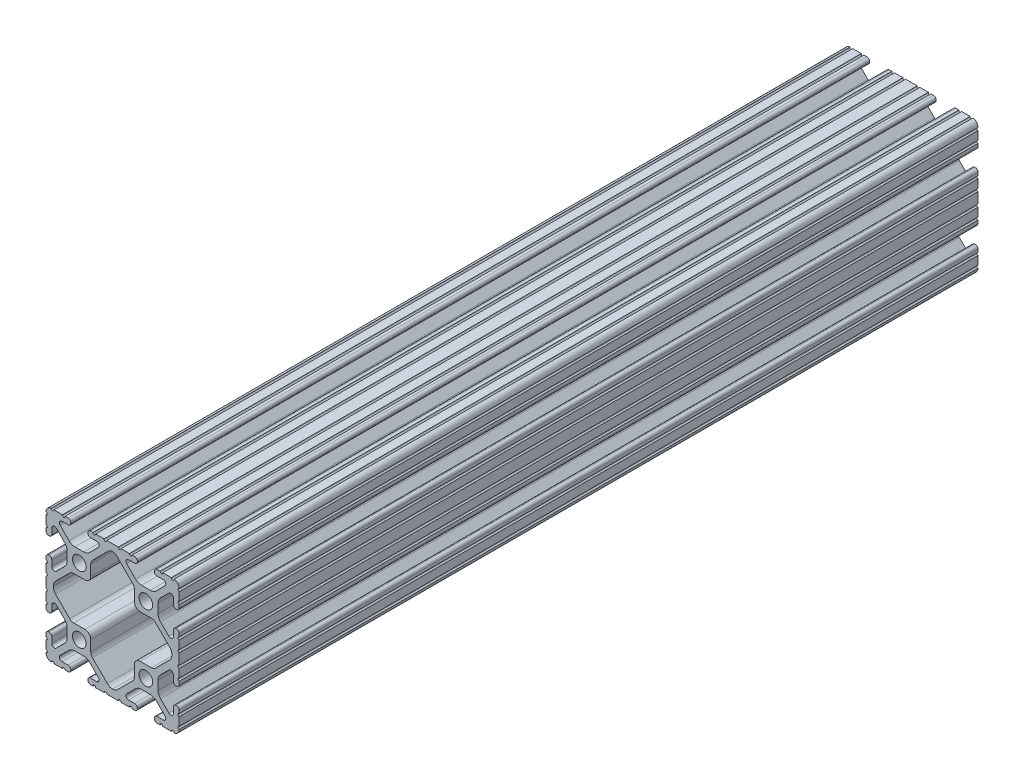
from build123d import *

# Parameters (mm, degrees)
SKETCH1_R      = 2.6035
EXTRUDE1_DEPTH = 304.8


with BuildPart() as part:
    # Sketch1 → Extrude1 (new body)
    with BuildSketch(Plane.XY):
        with BuildLine():
            Line((-2.210122516, -25.4), (2.210122516, -25.4))
            ThreePointArc((2.210122516, -25.4), (2.712319242, -24.815433371), (3.214515968, -25.4))
            Line((3.214515968, -25.4), (6.453532688, -25.4))
            ThreePointArc((6.453532688, -25.4), (6.955729414, -24.815433371), (7.45792614, -25.4))
            Line((7.45792614, -25.4), (8.405130016, -25.4))
            ThreePointArc((8.405130016, -25.4), (9.151169169, -25.100362415), (9.461500022, -24.358707602))
            Line((9.461500022, -24.358707602), (9.4615, -24.231492399))
            ThreePointArc((9.4615, -24.231492399), (9.151169155, -23.489837593), (8.405130016, -23.1902))
            Line((8.405130016, -23.1902), (6.087754002, -23.1902))
            ThreePointArc((6.087754002, -23.1902), (5.173448619, -22.579280675), (5.387974958, -21.500783941))
            Line((5.387974958, -21.500783941), (8.763022929, -18.12573597))
            ThreePointArc((8.763022929, -18.12573597), (9.793067061, -17.437482484), (11.008086959, -17.1958))
            Line((11.008086959, -17.1958), (14.391913041, -17.1958))
            ThreePointArc((14.391913041, -17.1958), (15.606932939, -17.437482484), (16.636977071, -18.12573597))
            Line((16.636977071, -18.12573597), (20.012025042, -21.500783941))
            ThreePointArc((20.012025042, -21.500783941), (20.223734168, -22.586011733), (19.297652818, -23.190092399))
            Line((19.297652818, -23.190092399), (16.9799, -23.190092399))
            ThreePointArc((16.9799, -23.190092399), (16.243518998, -23.495111397), (15.9385, -24.231492399))
            Line((15.9385, -24.231492399), (15.9385, -24.358492399))
            ThreePointArc((15.9385, -24.358492399), (16.248754204, -25.100286874), (16.994869984, -25.4))
            Line((16.994869984, -25.4), (18.134015685, -25.4))
            ThreePointArc((18.134015685, -25.4), (18.636212411, -24.815433371), (19.138409137, -25.4))
            Line((19.138409137, -25.4), (20.1295, -25.4))
            Line((20.1295, -25.4), (22.413213213, -25.4))
            ThreePointArc((22.413213213, -25.4), (22.915409939, -24.815433371), (23.417606664, -25.4))
            Line((23.417606664, -25.4), (23.450078724, -25.4))
            ThreePointArc((23.450078724, -25.4), (24.838729535, -24.730064765), (25.4, -23.294049529))
            Line((25.4, -23.294049529), (25.4, -23.268649529))
            ThreePointArc((25.4, -23.268649529), (24.892, -22.760649529), (25.4, -22.252649529))
            Line((25.4, -22.252649529), (25.4, -21.160449529))
            Line((25.4, -21.160449529), (25.4, -19.025239356))
            ThreePointArc((25.4, -19.025239356), (24.892, -18.517239356), (25.4, -18.009239356))
            Line((25.4, -18.009239356), (25.4, -16.91604181))
            ThreePointArc((25.4, -16.91604181), (25.094981002, -16.179660808), (24.3586, -15.87464181))
            Line((24.3586, -15.87464181), (24.2316, -15.87464181))
            ThreePointArc((24.2316, -15.87464181), (23.495218998, -16.179660808), (23.1902, -16.91604181))
            Line((23.1902, -16.91604181), (23.1902, -19.100988789))
            ThreePointArc((23.1902, -19.100988789), (22.563006367, -20.039650394), (21.45577951, -19.819409279))
            Line((21.45577951, -19.819409279), (18.27813597, -16.641765738))
            ThreePointArc((18.27813597, -16.641765738), (17.589882484, -15.611721606), (17.3482, -14.396701708))
            Line((17.3482, -14.396701708), (17.3482, -11.003495043))
            ThreePointArc((17.3482, -11.003495043), (17.590610762, -9.786718415), (18.280827, -8.755743204))
            Line((18.280827, -8.755743204), (21.45664064, -5.587529241))
            ThreePointArc((21.45664064, -5.587529241), (22.563568521, -5.368381274), (23.1902, -6.30680983))
            Line((23.1902, -6.30680983), (23.1902, -8.48395819))
            ThreePointArc((23.1902, -8.48395819), (23.495218998, -9.220339192), (24.2316, -9.52535819))
            Line((24.2316, -9.52535819), (24.3586, -9.52535819))
            ThreePointArc((24.3586, -9.52535819), (25.094981002, -9.220339192), (25.4, -8.48395819))
            Line((25.4, -8.48395819), (25.4, -7.327686685))
            ThreePointArc((25.4, -7.327686685), (24.892, -6.819686685), (25.4, -6.311686685))
            Line((25.4, -6.311686685), (25.4, -3.084276513))
            ThreePointArc((25.4, -3.084276513), (24.892, -2.576276513), (25.4, -2.068276513))
            Line((25.4, -2.068276513), (25.4, 2.068276513))
            ThreePointArc((25.4, 2.068276513), (24.892, 2.576276513), (25.4, 3.084276513))
            Line((25.4, 3.084276513), (25.4, 6.311686685))
            ThreePointArc((25.4, 6.311686685), (24.892, 6.819686685), (25.4, 7.327686685))
            Line((25.4, 7.327686685), (25.4, 8.48395819))
            ThreePointArc((25.4, 8.48395819), (25.094981002, 9.220339192), (24.3586, 9.52535819))
            Line((24.3586, 9.52535819), (24.2316, 9.52535819))
            ThreePointArc((24.2316, 9.52535819), (23.495218998, 9.220339192), (23.1902, 8.48395819))
            Line((23.1902, 8.48395819), (23.1902, 6.30680983))
            ThreePointArc((23.1902, 6.30680983), (22.563568521, 5.368381274), (21.45664064, 5.587529241))
            Line((21.45664064, 5.587529241), (18.280827, 8.755743204))
            ThreePointArc((18.280827, 8.755743204), (17.590610762, 9.786718415), (17.3482, 11.003495043))
            Line((17.3482, 11.003495043), (17.3482, 14.396701708))
            ThreePointArc((17.3482, 14.396701708), (17.589882484, 15.611721606), (18.27813597, 16.641765738))
            Line((18.27813597, 16.641765738), (21.45577951, 19.819409279))
            ThreePointArc((21.45577951, 19.819409279), (22.563006367, 20.039650394), (23.1902, 19.100988789))
            Line((23.1902, 19.100988789), (23.1902, 16.91604181))
            ThreePointArc((23.1902, 16.91604181), (23.495218998, 16.179660808), (24.2316, 15.87464181))
            Line((24.2316, 15.87464181), (24.3586, 15.87464181))
            ThreePointArc((24.3586, 15.87464181), (25.094981002, 16.179660808), (25.4, 16.91604181))
            Line((25.4, 16.91604181), (25.4, 18.009239356))
            ThreePointArc((25.4, 18.009239356), (24.892, 18.517239356), (25.4, 19.025239356))
            Line((25.4, 19.025239356), (25.4, 21.160449529))
            Line((25.4, 21.160449529), (25.4, 22.252649529))
            ThreePointArc((25.4, 22.252649529), (24.892, 22.760649529), (25.4, 23.268649529))
            Line((25.4, 23.268649529), (25.4, 23.294049529))
            ThreePointArc((25.4, 23.294049529), (24.838729535, 24.730064765), (23.450078724, 25.4))
            Line((23.450078724, 25.4), (23.417606664, 25.4))
            ThreePointArc((23.417606664, 25.4), (22.915409939, 24.815433371), (22.413213213, 25.4))
            Line((22.413213213, 25.4), (20.1295, 25.4))
            Line((20.1295, 25.4), (19.138409137, 25.4))
            ThreePointArc((19.138409137, 25.4), (18.636212411, 24.815433371), (18.134015685, 25.4))
            Line((18.134015685, 25.4), (16.994869984, 25.4))
            ThreePointArc((16.994869984, 25.4), (16.248754204, 25.100286874), (15.9385, 24.358492399))
            Line((15.9385, 24.358492399), (15.9385, 24.231492399))
            ThreePointArc((15.9385, 24.231492399), (16.243518998, 23.495111397), (16.9799, 23.190092399))
            Line((16.9799, 23.190092399), (19.297652818, 23.190092399))
            ThreePointArc((19.297652818, 23.190092399), (20.223734168, 22.586011733), (20.012025042, 21.500783941))
            Line((20.012025042, 21.500783941), (16.636977071, 18.12573597))
            ThreePointArc((16.636977071, 18.12573597), (15.606932939, 17.437482484), (14.391913041, 17.1958))
            Line((14.391913041, 17.1958), (11.008086959, 17.1958))
            ThreePointArc((11.008086959, 17.1958), (9.793067061, 17.437482484), (8.763022929, 18.12573597))
            Line((8.763022929, 18.12573597), (5.387974958, 21.500783941))
            ThreePointArc((5.387974958, 21.500783941), (5.173448619, 22.579280675), (6.087754002, 23.1902))
            Line((6.087754002, 23.1902), (8.405130016, 23.1902))
            ThreePointArc((8.405130016, 23.1902), (9.151169155, 23.489837593), (9.4615, 24.231492399))
            Line((9.4615, 24.231492399), (9.461500022, 24.358707602))
            ThreePointArc((9.461500022, 24.358707602), (9.151169169, 25.100362415), (8.405130016, 25.4))
            Line((8.405130016, 25.4), (7.45792614, 25.4))
            ThreePointArc((7.45792614, 25.4), (6.955729414, 24.815433371), (6.453532688, 25.4))
            Line((6.453532688, 25.4), (3.214515968, 25.4))
            ThreePointArc((3.214515968, 25.4), (2.712319242, 24.815433371), (2.210122516, 25.4))
            Line((2.210122516, 25.4), (-2.210122516, 25.4))
            ThreePointArc((-2.210122516, 25.4), (-2.712319242, 24.815433371), (-3.214515968, 25.4))
            Line((-3.214515968, 25.4), (-5.2705, 25.4))
            Line((-5.2705, 25.4), (-6.453532688, 25.4))
            ThreePointArc((-6.453532688, 25.4), (-6.955729414, 24.815433371), (-7.45792614, 25.4))
            Line((-7.45792614, 25.4), (-8.405130016, 25.4))
            ThreePointArc((-8.405130016, 25.4), (-9.151169169, 25.100362415), (-9.461500022, 24.358707602))
            Line((-9.461500022, 24.358707602), (-9.4615, 24.231492399))
            ThreePointArc((-9.4615, 24.231492399), (-9.151169155, 23.489837593), (-8.405130016, 23.1902))
            Line((-8.405130016, 23.1902), (-6.087754002, 23.1902))
            ThreePointArc((-6.087754002, 23.1902), (-5.173448619, 22.579280675), (-5.387974958, 21.500783941))
            Line((-5.387974958, 21.500783941), (-8.763022929, 18.12573597))
            ThreePointArc((-8.763022929, 18.12573597), (-9.793067061, 17.437482484), (-11.008086959, 17.1958))
            Line((-11.008086959, 17.1958), (-14.391913041, 17.1958))
            ThreePointArc((-14.391913041, 17.1958), (-15.606932939, 17.437482484), (-16.636977071, 18.12573597))
            Line((-16.636977071, 18.12573597), (-20.012025042, 21.500783941))
            ThreePointArc((-20.012025042, 21.500783941), (-20.223734168, 22.586011733), (-19.297652818, 23.190092399))
            Line((-19.297652818, 23.190092399), (-16.9799, 23.190092399))
            ThreePointArc((-16.9799, 23.190092399), (-16.243518998, 23.495111397), (-15.9385, 24.231492399))
            Line((-15.9385, 24.231492399), (-15.9385, 24.358492399))
            ThreePointArc((-15.9385, 24.358492399), (-16.248754204, 25.100286874), (-16.994869984, 25.4))
            Line((-16.994869984, 25.4), (-18.134015685, 25.4))
            ThreePointArc((-18.134015685, 25.4), (-18.636212411, 24.815433371), (-19.138409137, 25.4))
            Line((-19.138409137, 25.4), (-20.1295, 25.4))
            Line((-20.1295, 25.4), (-22.413213213, 25.4))
            ThreePointArc((-22.413213213, 25.4), (-22.915409939, 24.815433371), (-23.417606664, 25.4))
            Line((-23.417606664, 25.4), (-23.450078724, 25.4))
            ThreePointArc((-23.450078724, 25.4), (-24.838729535, 24.730064765), (-25.4, 23.294049529))
            Line((-25.4, 23.294049529), (-25.4, 23.268649529))
            ThreePointArc((-25.4, 23.268649529), (-24.892, 22.760649529), (-25.4, 22.252649529))
            Line((-25.4, 22.252649529), (-25.4, 21.160449529))
            Line((-25.4, 21.160449529), (-25.4, 19.025239356))
            ThreePointArc((-25.4, 19.025239356), (-24.892, 18.517239356), (-25.4, 18.009239356))
            Line((-25.4, 18.009239356), (-25.4, 16.91604181))
            ThreePointArc((-25.4, 16.91604181), (-25.094981002, 16.179660808), (-24.3586, 15.87464181))
            Line((-24.3586, 15.87464181), (-24.2316, 15.87464181))
            ThreePointArc((-24.2316, 15.87464181), (-23.495218998, 16.179660808), (-23.1902, 16.91604181))
            Line((-23.1902, 16.91604181), (-23.1902, 19.100988789))
            ThreePointArc((-23.1902, 19.100988789), (-22.563006367, 20.039650394), (-21.45577951, 19.819409279))
            Line((-21.45577951, 19.819409279), (-18.27813597, 16.641765738))
            ThreePointArc((-18.27813597, 16.641765738), (-17.589882484, 15.611721606), (-17.3482, 14.396701708))
            Line((-17.3482, 14.396701708), (-17.3482, 11.003495043))
            ThreePointArc((-17.3482, 11.003495043), (-17.590610762, 9.786718415), (-18.280827, 8.755743204))
            Line((-18.280827, 8.755743204), (-21.45664064, 5.587529241))
            ThreePointArc((-21.45664064, 5.587529241), (-22.563568521, 5.368381274), (-23.1902, 6.30680983))
            Line((-23.1902, 6.30680983), (-23.1902, 8.48395819))
            ThreePointArc((-23.1902, 8.48395819), (-23.495218998, 9.220339192), (-24.2316, 9.52535819))
            Line((-24.2316, 9.52535819), (-24.3586, 9.52535819))
            ThreePointArc((-24.3586, 9.52535819), (-25.094981002, 9.220339192), (-25.4, 8.48395819))
            Line((-25.4, 8.48395819), (-25.4, 7.327686685))
            ThreePointArc((-25.4, 7.327686685), (-24.892, 6.819686685), (-25.4, 6.311686685))
            Line((-25.4, 6.311686685), (-25.4, 3.084276513))
            ThreePointArc((-25.4, 3.084276513), (-24.892, 2.576276513), (-25.4, 2.068276513))
            Line((-25.4, 2.068276513), (-25.4, -2.068276513))
            ThreePointArc((-25.4, -2.068276513), (-24.892, -2.576276513), (-25.4, -3.084276513))
            Line((-25.4, -3.084276513), (-25.4, -4.176476513))
            Line((-25.4, -4.176476513), (-25.4, -6.311686685))
            ThreePointArc((-25.4, -6.311686685), (-24.892, -6.819686685), (-25.4, -7.327686685))
            Line((-25.4, -7.327686685), (-25.4, -8.48395819))
            ThreePointArc((-25.4, -8.48395819), (-25.094981002, -9.220339192), (-24.3586, -9.52535819))
            Line((-24.3586, -9.52535819), (-24.2316, -9.52535819))
            ThreePointArc((-24.2316, -9.52535819), (-23.495218998, -9.220339192), (-23.1902, -8.48395819))
            Line((-23.1902, -8.48395819), (-23.1902, -6.30680983))
            ThreePointArc((-23.1902, -6.30680983), (-22.563568521, -5.368381274), (-21.45664064, -5.587529241))
            Line((-21.45664064, -5.587529241), (-18.280827, -8.755743204))
            ThreePointArc((-18.280827, -8.755743204), (-17.590610762, -9.786718415), (-17.3482, -11.003495043))
            Line((-17.3482, -11.003495043), (-17.3482, -14.396701708))
            ThreePointArc((-17.3482, -14.396701708), (-17.589882484, -15.611721606), (-18.27813597, -16.641765738))
            Line((-18.27813597, -16.641765738), (-21.45577951, -19.819409279))
            ThreePointArc((-21.45577951, -19.819409279), (-22.563006367, -20.039650394), (-23.1902, -19.100988789))
            Line((-23.1902, -19.100988789), (-23.1902, -16.91604181))
            ThreePointArc((-23.1902, -16.91604181), (-23.495218998, -16.179660808), (-24.2316, -15.87464181))
            Line((-24.2316, -15.87464181), (-24.3586, -15.87464181))
            ThreePointArc((-24.3586, -15.87464181), (-25.094981002, -16.179660808), (-25.4, -16.91604181))
            Line((-25.4, -16.91604181), (-25.4, -18.009239356))
            ThreePointArc((-25.4, -18.009239356), (-24.892, -18.517239356), (-25.4, -19.025239356))
            Line((-25.4, -19.025239356), (-25.4, -21.160449529))
            Line((-25.4, -21.160449529), (-25.4, -22.252649529))
            ThreePointArc((-25.4, -22.252649529), (-24.892, -22.760649529), (-25.4, -23.268649529))
            Line((-25.4, -23.268649529), (-25.4, -23.294049529))
            ThreePointArc((-25.4, -23.294049529), (-24.838729535, -24.730064765), (-23.450078724, -25.4))
            Line((-23.450078724, -25.4), (-23.417606664, -25.4))
            ThreePointArc((-23.417606664, -25.4), (-22.915409939, -24.815433371), (-22.413213213, -25.4))
            Line((-22.413213213, -25.4), (-20.1295, -25.4))
            Line((-20.1295, -25.4), (-19.138409137, -25.4))
            ThreePointArc((-19.138409137, -25.4), (-18.636212411, -24.815433371), (-18.134015685, -25.4))
            Line((-18.134015685, -25.4), (-16.994869984, -25.4))
            ThreePointArc((-16.994869984, -25.4), (-16.248754204, -25.100286874), (-15.9385, -24.358492399))
            Line((-15.9385, -24.358492399), (-15.9385, -24.231492399))
            ThreePointArc((-15.9385, -24.231492399), (-16.243518998, -23.495111397), (-16.9799, -23.190092399))
            Line((-16.9799, -23.190092399), (-19.297652818, -23.190092399))
            ThreePointArc((-19.297652818, -23.190092399), (-20.223734168, -22.586011733), (-20.012025042, -21.500783941))
            Line((-20.012025042, -21.500783941), (-16.636977071, -18.12573597))
            ThreePointArc((-16.636977071, -18.12573597), (-15.606932939, -17.437482484), (-14.391913041, -17.1958))
            Line((-14.391913041, -17.1958), (-11.008086959, -17.1958))
            ThreePointArc((-11.008086959, -17.1958), (-9.793067061, -17.437482484), (-8.763022929, -18.12573597))
            Line((-8.763022929, -18.12573597), (-5.387974958, -21.500783941))
            ThreePointArc((-5.387974958, -21.500783941), (-5.173448619, -22.579280675), (-6.087754002, -23.1902))
            Line((-6.087754002, -23.1902), (-8.405130016, -23.1902))
            ThreePointArc((-8.405130016, -23.1902), (-9.151169155, -23.489837593), (-9.4615, -24.231492399))
            Line((-9.4615, -24.231492399), (-9.461500022, -24.358707602))
            ThreePointArc((-9.461500022, -24.358707602), (-9.151169169, -25.100362415), (-8.405130016, -25.4))
            Line((-8.405130016, -25.4), (-7.45792614, -25.4))
            ThreePointArc((-7.45792614, -25.4), (-6.955729414, -24.815433371), (-6.453532688, -25.4))
            Line((-6.453532688, -25.4), (-5.2705, -25.4))
            Line((-5.2705, -25.4), (-3.214515968, -25.4))
            ThreePointArc((-3.214515968, -25.4), (-2.712319242, -24.815433371), (-2.210122516, -25.4))
        make_face()
        with Locations((12.7, -12.7)):
            Circle(SKETCH1_R, mode=Mode.SUBTRACT)
        with Locations((-12.7, -12.7)):
            Circle(SKETCH1_R, mode=Mode.SUBTRACT)
        with Locations((-12.7, 12.7)):
            Circle(SKETCH1_R, mode=Mode.SUBTRACT)
        with Locations((12.7, 12.7)):
            Circle(SKETCH1_R, mode=Mode.SUBTRACT)
        with BuildLine():
            Line((-1.987770861, -21.775858908), (-7.683964565, -16.079665203))
            ThreePointArc((-7.683964565, -16.079665203), (-8.162988991, -15.362754487), (-8.3312, -14.517100638))
            Line((-8.3312, -14.517100638), (-8.3312, -10.3886))
            ThreePointArc((-8.3312, -10.3886), (-8.978435435, -8.826035435), (-10.541, -8.1788))
            Line((-10.541, -8.1788), (-14.816495758, -8.1788))
            ThreePointArc((-14.816495758, -8.1788), (-15.66092662, -8.01109514), (-16.377187366, -7.53343528))
            Line((-16.377187366, -7.53343528), (-21.77338316, -2.150152507))
            ThreePointArc((-21.77338316, -2.150152507), (-22.408382099, -1.201655313), (-22.6314, -0.082220815))
            Line((-22.6314, -0.082220815), (-22.6314, 0.082220815))
            ThreePointArc((-22.6314, 0.082220815), (-22.408382099, 1.201655313), (-21.77338316, 2.150152507))
            Line((-21.77338316, 2.150152507), (-16.377187366, 7.53343528))
            ThreePointArc((-16.377187366, 7.53343528), (-15.66092662, 8.01109514), (-14.816495758, 8.1788))
            Line((-14.816495758, 8.1788), (-10.541, 8.1788))
            ThreePointArc((-10.541, 8.1788), (-8.978435435, 8.826035435), (-8.3312, 10.3886))
            Line((-8.3312, 10.3886), (-8.3312, 14.517100638))
            ThreePointArc((-8.3312, 14.517100638), (-8.162988991, 15.362754487), (-7.683964565, 16.079665203))
            Line((-7.683964565, 16.079665203), (-1.795557487, 21.968072281))
            ThreePointArc((-1.795557487, 21.968072281), (-0.97153248, 22.546678968), (0, 22.811117151))
            ThreePointArc((0, 22.811117151), (0.97153248, 22.546678968), (1.795557487, 21.968072281))
            Line((1.795557487, 21.968072281), (7.683964565, 16.079665203))
            ThreePointArc((7.683964565, 16.079665203), (8.162988991, 15.362754487), (8.3312, 14.517100638))
            Line((8.3312, 14.517100638), (8.3312, 12.700098375))
            Line((8.3312, 12.700098375), (8.3312, 10.389032234))
            ThreePointArc((8.3312, 10.389032234), (8.978435435, 8.826467669), (10.541, 8.179232234))
            Line((10.541, 8.179232234), (14.816062488, 8.179232234))
            ThreePointArc((14.816062488, 8.179232234), (15.660493349, 8.011527374), (16.376754096, 7.533867514))
            Line((16.376754096, 7.533867514), (21.77338316, 2.150152507))
            ThreePointArc((21.77338316, 2.150152507), (22.408382099, 1.201655313), (22.6314, 0.082220815))
            Line((22.6314, 0.082220815), (22.6314, -0.082220815))
            ThreePointArc((22.6314, -0.082220815), (22.408382099, -1.201655313), (21.77338316, -2.150152507))
            Line((21.77338316, -2.150152507), (16.377187366, -7.53343528))
            ThreePointArc((16.377187366, -7.53343528), (15.66092662, -8.01109514), (14.816495758, -8.1788))
            Line((14.816495758, -8.1788), (10.541, -8.1788))
            ThreePointArc((10.541, -8.1788), (8.978435435, -8.826035435), (8.3312, -10.3886))
            Line((8.3312, -10.3886), (8.3312, -14.517100638))
            ThreePointArc((8.3312, -14.517100638), (8.162988991, -15.362754487), (7.683964565, -16.079665203))
            Line((7.683964565, -16.079665203), (1.987770861, -21.775858908))
            ThreePointArc((1.987770861, -21.775858908), (1.075921771, -22.393947165), (0, -22.630366707))
            ThreePointArc((0, -22.630366707), (-1.075921771, -22.393947165), (-1.987770861, -21.775858908))
        make_face(mode=Mode.SUBTRACT)
    extrude(amount=-EXTRUDE1_DEPTH)


solid = part.part
